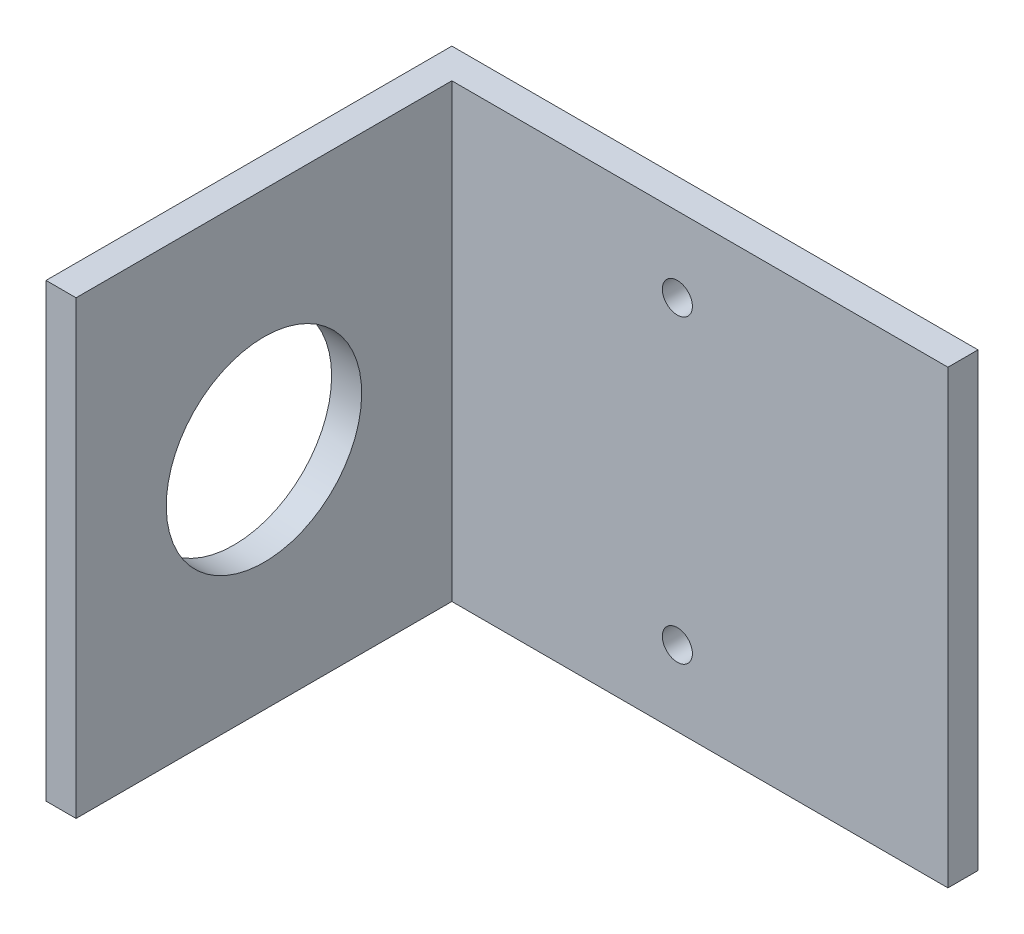
from build123d import *

# Parameters (mm, degrees)
SKETCH1_W           = 70
SKETCH1_H           = 60
BOSS_EXTRUDE1_DEPTH = 4
SKETCH2_W           = 4
SKETCH2_H           = 60
BOSS_EXTRUDE2_DEPTH = 50
SKETCH3_R           = 13
CUT_EXTRUDE1_DEPTH  = 50
SKETCH4_R           = 2
CUT_EXTRUDE2_DEPTH  = 50


with BuildPart() as part:
    # Sketch1 → Boss-Extrude1 (new body)
    with BuildSketch(Plane.XY):
        Rectangle(SKETCH1_W, SKETCH1_H)
    extrude(amount=BOSS_EXTRUDE1_DEPTH)

    # Sketch2 → Boss-Extrude2 (add)
    with BuildSketch(Plane.XY.offset(4)):
        with Locations((-33, 0)):
            Rectangle(SKETCH2_W, SKETCH2_H)
    extrude(amount=BOSS_EXTRUDE2_DEPTH)

    # Sketch3 → Cut-Extrude1 (cut)
    with BuildSketch(Plane(origin=(-31, 0, 0), x_dir=(0, 0, -1), z_dir=(1, 0, 0))):
        with Locations((-29, 0)):
            Circle(SKETCH3_R)
    extrude(amount=-CUT_EXTRUDE1_DEPTH, mode=Mode.SUBTRACT)

    # Sketch4 → Cut-Extrude2 (cut)
    with BuildSketch(Plane.XY.offset(4)):
        with Locations((-1, 20)):
            Circle(SKETCH4_R)
        with Locations((-1, -20)):
            Circle(SKETCH4_R)
    extrude(amount=-CUT_EXTRUDE2_DEPTH, mode=Mode.SUBTRACT)


solid = part.part
